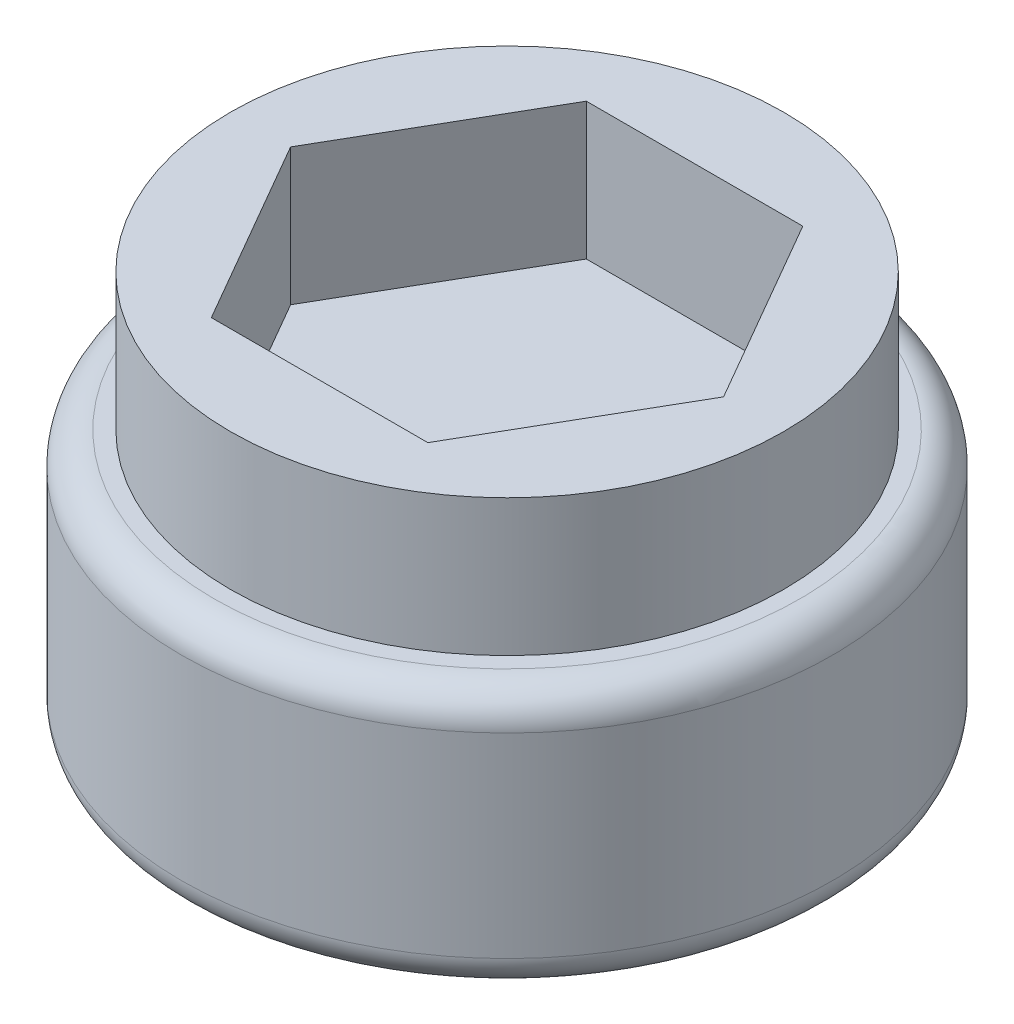
from build123d import *
from OCP.BRepFilletAPI import BRepFilletAPI_MakeChamfer

# Parameters (mm, degrees)
BOSS_EXTRUDE1_DEPTH  = 1.75
BOSS_EXTRUDE2_DEPTH  = 0.5
BOSS_EXTRUDE5_DEPTH  = 3.5
SKETCH4_R            = 3.5
BOSS_EXTRUDE7_DEPTH  = 2
SKETCH11_R           = 4.505443821
SKETCH11_R_2         = 3.5
CUT_EXTRUDE3_DEPTH   = 2
SKETCH12_R           = 3.5
CUT_EXTRUDE4_DEPTH   = 3
BOSS_EXTRUDE8_DEPTH  = 2.5
CHAMFER1_SIZE        = 0.5
CHAMFER1_SIZE2       = 0.288675135
SKETCH17_R           = 3.25
BOSS_EXTRUDE9_DEPTH  = 3
SKETCH18_R           = 1.768100224
CUT_EXTRUDE8_DEPTH   = 2.25
SKETCH20_R           = 5
BOSS_EXTRUDE10_DEPTH = 2
SKETCH21_R           = 5
BOSS_EXTRUDE11_DEPTH = 2
FILLET1_R            = 0.5
SKETCH25_R           = 4.000350088
CUT_EXTRUDE9_DEPTH   = 10
SKETCH26_R           = 4.25
BOSS_EXTRUDE12_DEPTH = 2.1


with BuildPart() as part:
    # Sketch1 → Boss-Extrude1 (new body)
    with BuildSketch(Plane(origin=(0, 0, 0), x_dir=(1, 0, 0), z_dir=(0, 1, 0))):
        Polygon((0.658179307, 0), (0.329089653, 0.57), (-0.329089653, 0.57), (-0.658179307, 0), (-0.329089653, -0.57), (0.329089653, -0.57), align=None)
    extrude(amount=BOSS_EXTRUDE1_DEPTH)

    # Sketch2 → Boss-Extrude2 (add)
    with BuildSketch(Plane(origin=(0, 1.75, 0), x_dir=(1, 0, 0), z_dir=(0, 1, 0))):
        Polygon((0.658179307, 0), (0.558124156, -0.173300605), (4.375, 0), (0.558578548, 0.172513574), align=None)
        Polygon((0, 0.197762982), (0, 0), (0, -0.198641554), (0.558124156, -0.173300605), (0.658179307, 0), (0.558578548, 0.172513574), align=None)
    extrude(amount=BOSS_EXTRUDE2_DEPTH)

    # Sketch3 → Boss-Extrude5 (add)
    with BuildSketch(Plane(origin=(0, 1.75, 0), x_dir=(1, 0, 0), z_dir=(0, 1, 0))):
        Polygon((0.658179307, 0), (0.329089653, 0.57), (-0.329089653, 0.57), (-0.658179307, 0), (-0.329089653, -0.57), (0.329089653, -0.57), align=None)
    extrude(amount=BOSS_EXTRUDE5_DEPTH)

    # Sketch4 → Boss-Extrude7 (add)
    with BuildSketch(Plane(origin=(0, 5.25, 0), x_dir=(1, 0, 0), z_dir=(0, 1, 0))):
        with Locations(Location((0, 0, 0), (0, 0, 270))):
            Circle(SKETCH4_R)
    extrude(amount=BOSS_EXTRUDE7_DEPTH)

    # Sketch11 → Cut-Extrude3 (cut)
    with BuildSketch(Plane(origin=(0, 1.75, 0), x_dir=(-1, 0, 0), z_dir=(0, -1, 0))):
        Circle(SKETCH11_R)
        with Locations(Location((0, 0, 0), (0, 0, 270))):
            Circle(SKETCH11_R_2, mode=Mode.SUBTRACT)
    extrude(amount=-CUT_EXTRUDE3_DEPTH, mode=Mode.SUBTRACT)

    # Sketch12 → Cut-Extrude4 (cut)
    with BuildSketch(Plane(origin=(0, 0, 0), x_dir=(-1, 0, 0), z_dir=(0, -1, 0))):
        with Locations(Location((0, 0, 0), (0, 0, 270))):
            Circle(SKETCH12_R)
    extrude(amount=-CUT_EXTRUDE4_DEPTH, mode=Mode.SUBTRACT)

    # Sketch16 → Boss-Extrude8 (add)
    with BuildSketch(Plane(origin=(0, 3, 0), x_dir=(-1, 0, 0), z_dir=(0, -1, 0))):
        Polygon((0.55, -0.952627944), (1.1, 0), (0.658179307, 0), (0.329089653, -0.57), (-0.329089653, -0.57), (-0.658179307, 0), (-1.1, 0), (-0.55, -0.952627944), align=None)
        Polygon((0.658179307, 0), (1.1, 0), (0.55, 0.952627944), (-0.55, 0.952627944), (-1.1, 0), (-0.658179307, 0), (-0.329089653, 0.57), (0.329089653, 0.57), align=None)
        Polygon((-0.658179307, 0), (0.658179307, 0), (0.329089653, 0.57), (-0.329089653, 0.57), align=None)
        Polygon((0.329089653, -0.57), (0.658179307, 0), (-0.658179307, 0), (-0.329089653, -0.57), align=None)
    extrude(amount=-BOSS_EXTRUDE8_DEPTH)

    # Chamfer1: one chamfer whose edges measure the first distance from different faces: ONE call of the kernel's chamfer builder (chamfer() names one face for all edges)
    chamfer1_edges_1 = [part.edges().sort_by_distance(p)[0] for p in [
        (-0.825, 5.25, -0.476313972),
    ]]
    chamfer1_side_1 = [part.faces().sort_by_distance(p)[0] for p in [
        (-0.825, 4.125, -0.476313972),
    ]]
    chamfer1_edges_2 = [part.edges().sort_by_distance(p)[0] for p in [
        (0, 5.25, -0.952627944),
    ]]
    chamfer1_side_2 = [part.faces().sort_by_distance(p)[0] for p in [
        (0, 4.125, -0.952627944),
    ]]
    chamfer1_edges_3 = [part.edges().sort_by_distance(p)[0] for p in [
        (0.825, 5.25, -0.476313972),
    ]]
    chamfer1_side_3 = [part.faces().sort_by_distance(p)[0] for p in [
        (0.825, 4.125, -0.476313972),
    ]]
    chamfer1_edges_4 = [part.edges().sort_by_distance(p)[0] for p in [
        (0.825, 5.25, 0.476313972),
    ]]
    chamfer1_side_4 = [part.faces().sort_by_distance(p)[0] for p in [
        (0.825, 4.125, 0.476313972),
    ]]
    chamfer1_edges_5 = [part.edges().sort_by_distance(p)[0] for p in [
        (0, 5.25, 0.952627944),
    ]]
    chamfer1_side_5 = [part.faces().sort_by_distance(p)[0] for p in [
        (0, 4.125, 0.952627944),
    ]]
    chamfer1_edges_6 = [part.edges().sort_by_distance(p)[0] for p in [
        (-0.825, 5.25, 0.476313972),
    ]]
    chamfer1_side_6 = [part.faces().sort_by_distance(p)[0] for p in [
        (-0.825, 4.125, 0.476313972),
    ]]
    chamfer1 = BRepFilletAPI_MakeChamfer(part.part.solid().wrapped)
    for e in chamfer1_edges_1:
        chamfer1.Add(CHAMFER1_SIZE, CHAMFER1_SIZE2, e.wrapped, chamfer1_side_1[0].wrapped)  # the first distance lies on this face
    for e in chamfer1_edges_2:
        chamfer1.Add(CHAMFER1_SIZE, CHAMFER1_SIZE2, e.wrapped, chamfer1_side_2[0].wrapped)  # the first distance lies on this face
    for e in chamfer1_edges_3:
        chamfer1.Add(CHAMFER1_SIZE, CHAMFER1_SIZE2, e.wrapped, chamfer1_side_3[0].wrapped)  # the first distance lies on this face
    for e in chamfer1_edges_4:
        chamfer1.Add(CHAMFER1_SIZE, CHAMFER1_SIZE2, e.wrapped, chamfer1_side_4[0].wrapped)  # the first distance lies on this face
    for e in chamfer1_edges_5:
        chamfer1.Add(CHAMFER1_SIZE, CHAMFER1_SIZE2, e.wrapped, chamfer1_side_5[0].wrapped)  # the first distance lies on this face
    for e in chamfer1_edges_6:
        chamfer1.Add(CHAMFER1_SIZE, CHAMFER1_SIZE2, e.wrapped, chamfer1_side_6[0].wrapped)  # the first distance lies on this face
    add(Compound.cast(chamfer1.Shape()), mode=Mode.REPLACE)

    # Sketch17 → Boss-Extrude9 (add)
    with BuildSketch(Plane(origin=(0, 3, 0), x_dir=(-1, 0, 0), z_dir=(0, -1, 0))):
        with Locations(Location((0, 0, 0), (0, 0, 90))):
            Circle(SKETCH17_R)
        Polygon((-2.995914926, 0), (-1.497957463, -2.594538434), (1.497957463, -2.594538434), (2.995914926, 0), (1.497957463, 2.594538434), (-1.497957463, 2.594538434), align=None, mode=Mode.SUBTRACT)
    extrude(amount=-BOSS_EXTRUDE9_DEPTH)

    # Sketch18 → Cut-Extrude8 (cut)
    with BuildSketch(Plane(origin=(0, 3, 0), x_dir=(-1, 0, 0), z_dir=(0, -1, 0))):
        Circle(SKETCH18_R)
    extrude(amount=-CUT_EXTRUDE8_DEPTH, mode=Mode.SUBTRACT)

    # Sketch20 → Boss-Extrude10 (add)
    with BuildSketch(Plane(origin=(0, 7.25, 0), x_dir=(1, 0, 0), z_dir=(0, 1, 0))):
        with Locations(Location((0, 0, 0), (0, 0, 270))):
            Circle(SKETCH20_R)
    extrude(amount=-BOSS_EXTRUDE10_DEPTH)

    # Sketch21 → Boss-Extrude11 (add)
    with BuildSketch(Plane(origin=(0, 7.25, 0), x_dir=(1, 0, 0), z_dir=(0, 1, 0))):
        with Locations(Location((0, 0, 0), (0, 0, 270))):
            Circle(SKETCH21_R)
    extrude(amount=BOSS_EXTRUDE11_DEPTH)

    # Fillet1
    fillet1_edges = [part.edges().sort_by_distance(p)[0] for p in [
        (0, 5.25, -5),
        (0, 9.25, -5),
    ]]
    fillet(fillet1_edges, radius=FILLET1_R)

    # Sketch25 → Cut-Extrude9 (cut)
    with BuildSketch(Plane(origin=(0, 5.25, 0), x_dir=(-1, 0, 0), z_dir=(0, -1, 0))):
        Circle(SKETCH25_R)
    extrude(amount=CUT_EXTRUDE9_DEPTH, mode=Mode.SUBTRACT)

    # Sketch26 → Boss-Extrude12 (add)
    with BuildSketch(Plane(origin=(0, 9.25, 0), x_dir=(1, 0, 0), z_dir=(0, 1, 0))):
        with Locations(Location((0, 0, 0), (0, 0, 270))):
            Circle(SKETCH26_R)
        Polygon((1.662768775, -2.88), (3.325537551, 0), (1.662768775, 2.88), (-1.662768775, 2.88), (-3.325537551, 0), (-1.662768775, -2.88), align=None, mode=Mode.SUBTRACT)
    extrude(amount=BOSS_EXTRUDE12_DEPTH)


solid = part.part
